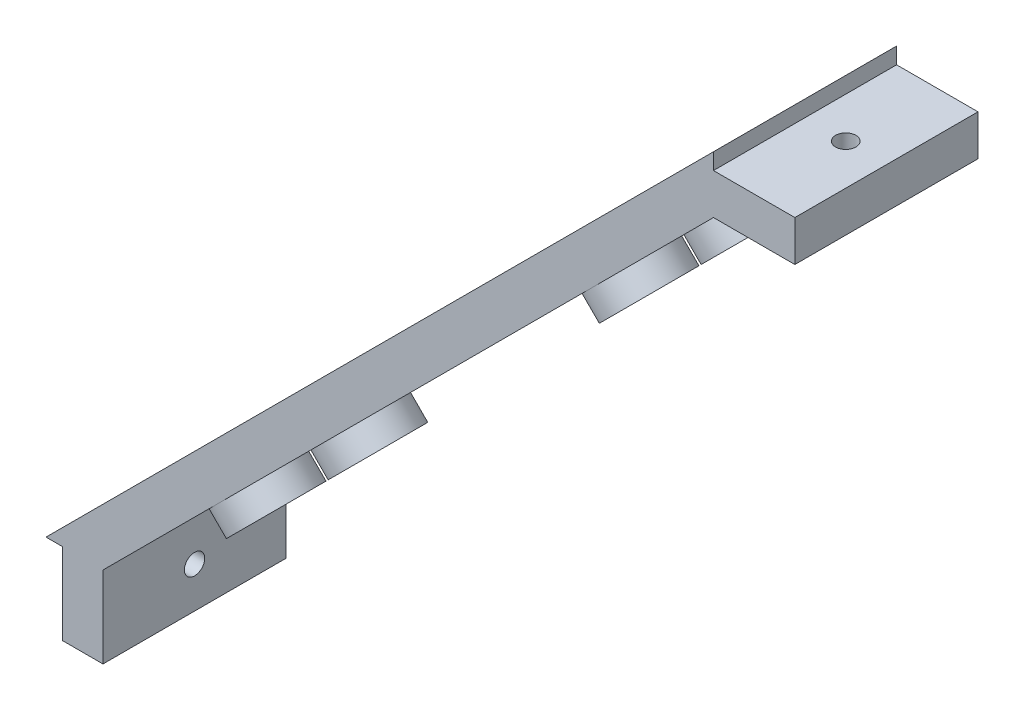
from build123d import *

# Parameters (mm, degrees)
MAIN_DEPTH                = 11.25
SKETCH2_R                 = 1.25
FIXHOLE1_DEPTH            = 83
SKETCH3_R                 = 1.25
FIXHOLE2_DEPTH            = 83
SKETCH6_R                 = 1.25
CUT_EXTRUDE2_DEPTH        = 63.932503526
LPATTERN1_COUNT           = 5
LPATTERN1_PITCH           = 20
SKETCH7_R                 = 5
BOSS_EXTRUDE1_DEPTH       = 3
SKETCH8_R                 = 1.25
CUT_EXTRUDE3_DEPTH        = 66.932503526
LPATTERN2_COUNT           = 2
LPATTERN2_PITCH           = 12.5
LPATTERN2_COPY_1_SKETCH_R = 1.25
LPATTERN2_COPY_1_DEPTH    = 63.932503526
LPATTERN2_COPY_2_SKETCH_R = 1.25
LPATTERN2_COPY_2_DEPTH    = 63.932503526
LPATTERN2_COPY_3_SKETCH_R = 1.25
LPATTERN2_COPY_3_DEPTH    = 63.932503526
LPATTERN2_COPY_4_SKETCH_R = 1.25
LPATTERN2_COPY_4_DEPTH    = 63.932503526


with BuildPart() as part:
    # Sketch1 → Main (new body, symmetric)
    with BuildSketch(Plane.XY):
        Polygon((-41, -41), (41, 41), (41, 39), (51, 39), (51, 34), (41, 34), (-34, -41), (-34, -51), (-39, -51), (-39, -41), align=None)
    extrude(amount=MAIN_DEPTH, both=True)

    # Sketch2 → FixHole1 (cut, through all)
    with BuildSketch(Plane(origin=(41, 0, 0), x_dir=(0, 0, -1), z_dir=(1, 0, 0))):
        with Locations((0, -46)):
            Circle(SKETCH2_R)
    extrude(amount=-FIXHOLE1_DEPTH, mode=Mode.SUBTRACT)

    # Sketch3 → FixHole2 (cut, through all)
    with BuildSketch(Plane(origin=(0, -41, 0), x_dir=(-1, 0, 0), z_dir=(0, -1, 0))):
        with Locations((-46, 0)):
            Circle(SKETCH3_R)
    extrude(amount=-FIXHOLE2_DEPTH, mode=Mode.SUBTRACT)

    # Sketch6 → Cut-Extrude2 (cut, through all)
    with BuildSketch(Plane(origin=(3.5, -3.5, 0), x_dir=(0, 0, 1), z_dir=(-0.707106781, 0.707106781, 0))):
        with Locations((-6.25, 40)):
            Circle(SKETCH6_R)
    cut_extrude2 = extrude(amount=CUT_EXTRUDE2_DEPTH, mode=Mode.SUBTRACT)

    # LPattern1: Cut-Extrude2 ×5
    with Locations(*[Vector(-0.707106781, -0.707106781, 0) * (i * LPATTERN1_PITCH) for i in range(1, LPATTERN1_COUNT)]):
        add(cut_extrude2, mode=Mode.SUBTRACT)

    # Sketch7 → Boss-Extrude1 (add)
    with BuildSketch(Plane(origin=(3.5, -3.5, 0), x_dir=(0, 0, 1), z_dir=(-0.707106781, 0.707106781, 0))):
        with Locations((-6.25, -33.008531019)):
            Circle(SKETCH7_R)
        with Locations((-6.25, 31.791468981)):
            Circle(SKETCH7_R)
    boss_extrude1 = extrude(amount=-BOSS_EXTRUDE1_DEPTH)

    # Sketch8 → Cut-Extrude3 (cut, through all)
    with BuildSketch(Plane(origin=(5.621320344, -5.621320344, 0), x_dir=(0, 0, -1), z_dir=(0.707106781, -0.707106781, 0))):
        with Locations((6.25, 31.791468981)):
            Circle(SKETCH8_R)
        with Locations((6.25, -33.008531019)):
            Circle(SKETCH8_R)
    cut_extrude3 = extrude(amount=-CUT_EXTRUDE3_DEPTH, mode=Mode.SUBTRACT)

    # LPattern2: Boss-Extrude1, Cut-Extrude3, Cut-Extrude2 ×2
    with Locations(*[(0, 0, i * LPATTERN2_PITCH) for i in range(1, LPATTERN2_COUNT)]):
        add(boss_extrude1)
        add(cut_extrude3, mode=Mode.SUBTRACT)
        add(cut_extrude2, mode=Mode.SUBTRACT)

    # LPattern2 copy 1 sketch → LPattern2 copy 1 (cut, through all)
    with BuildSketch(Plane(origin=(-10.642135624, -17.642135624, 12.5), x_dir=(0, 0, 1), z_dir=(-0.707106781, 0.707106781, 0))):
        with Locations((-6.25, 40)):
            Circle(LPATTERN2_COPY_1_SKETCH_R)
    extrude(amount=LPATTERN2_COPY_1_DEPTH, mode=Mode.SUBTRACT)

    # LPattern2 copy 2 sketch → LPattern2 copy 2 (cut, through all)
    with BuildSketch(Plane(origin=(-24.784271247, -31.784271247, 12.5), x_dir=(0, 0, 1), z_dir=(-0.707106781, 0.707106781, 0))):
        with Locations((-6.25, 40)):
            Circle(LPATTERN2_COPY_2_SKETCH_R)
    extrude(amount=LPATTERN2_COPY_2_DEPTH, mode=Mode.SUBTRACT)

    # LPattern2 copy 3 sketch → LPattern2 copy 3 (cut, through all)
    with BuildSketch(Plane(origin=(-38.926406871, -45.926406871, 12.5), x_dir=(0, 0, 1), z_dir=(-0.707106781, 0.707106781, 0))):
        with Locations((-6.25, 40)):
            Circle(LPATTERN2_COPY_3_SKETCH_R)
    extrude(amount=LPATTERN2_COPY_3_DEPTH, mode=Mode.SUBTRACT)

    # LPattern2 copy 4 sketch → LPattern2 copy 4 (cut, through all)
    with BuildSketch(Plane(origin=(-53.068542495, -60.068542495, 12.5), x_dir=(0, 0, 1), z_dir=(-0.707106781, 0.707106781, 0))):
        with Locations((-6.25, 40)):
            Circle(LPATTERN2_COPY_4_SKETCH_R)
    extrude(amount=LPATTERN2_COPY_4_DEPTH, mode=Mode.SUBTRACT)


solid = part.part
